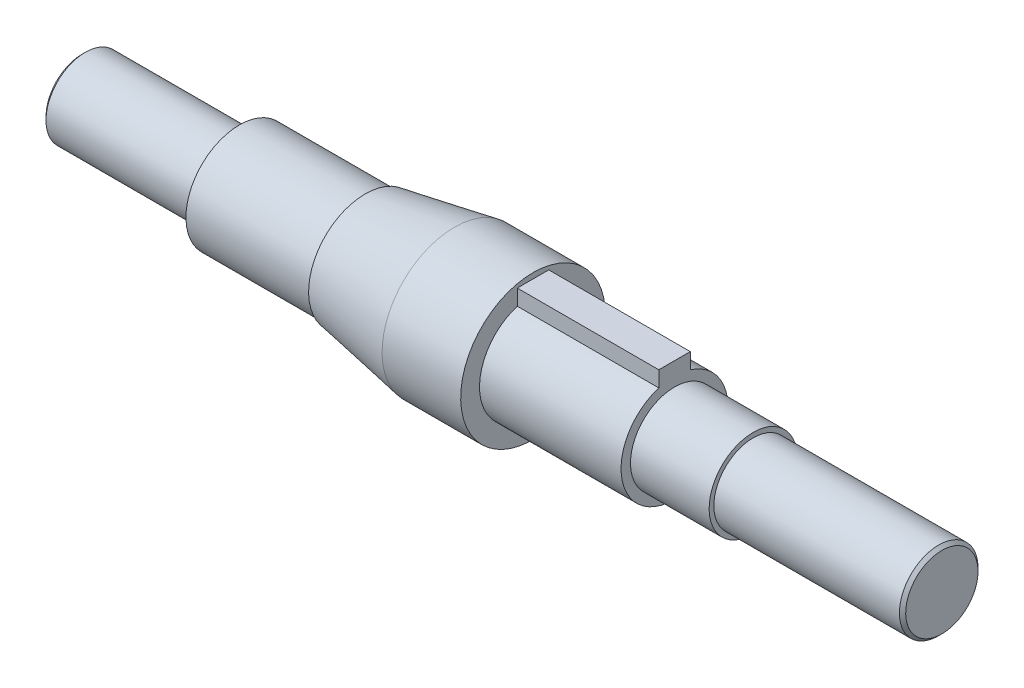
from build123d import *

# Parameters (mm, degrees)
SKETCH3_W           = 10
SKETCH3_H           = 5
BOSS_EXTRUDE1_DEPTH = 45
CHAMFER1_SIZE       = 1


with BuildPart() as part:
    # Sketch1 → Revolve1 (revolve)
    with BuildSketch(Plane.XY):
        Polygon((-136.678204549, 12.5), (-86.678204549, 12.5), (-86.678204549, 17), (-46.678204549, 17), (-46.678204549, 18), (-18.321795451, 23), (6.678204549, 23), (6.678204549, 17), (51.678204549, 17), (51.678204549, 14), (76.678204549, 14), (76.678204549, 12.5), (136.678204549, 12.5), (136.678204549, 0), (-136.678204549, 0), align=None)
    revolve(axis=Axis((136.678204549, 0, 0), (-1, 0, 0)))

    # Sketch3 → Boss-Extrude1 (add)
    with BuildSketch(Plane(origin=(51.678204549, 0, 0), x_dir=(0, 0, -1), z_dir=(1, 0, 0))):
        with Locations((0, 18.748076809)):
            Rectangle(SKETCH3_W, SKETCH3_H)
    extrude(amount=-BOSS_EXTRUDE1_DEPTH)

    # Chamfer1
    chamfer1_edges = [part.edges().sort_by_distance(p)[0] for p in [
        (136.678204549, -12.5, 0),
        (-136.678204549, -12.5, 0),
    ]]
    chamfer(chamfer1_edges, length=CHAMFER1_SIZE)


solid = part.part
